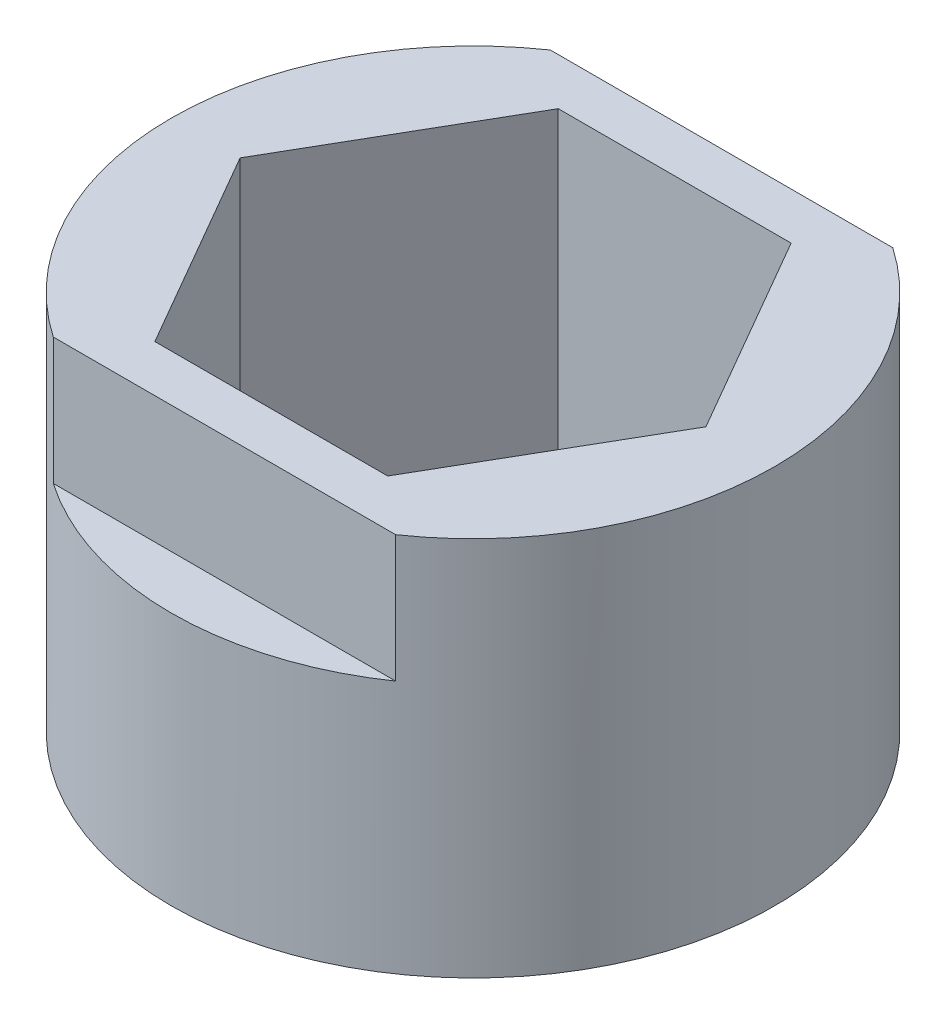
from build123d import *

# Parameters (mm, degrees)
SKETCH1_R               = 7.5565
BOSS_EXTRUDE1_DEPTH     = 8.89
SKETCH2_R               = 7.5565
SKETCH2_R_2             = 3.3
BOSS_EXTRUDE2_DEPTH     = 0.635
SKETCH3_W               = 1.979009817
SKETCH3_H               = 3.81
SKETCH3_W_2             = 2.256055482
CUT_EXTRUDE1_DEPTH      = 8.5565
CUT_EXTRUDE1_DEPTH_BACK = 8.5565


with BuildPart() as part:
    # Sketch1 → Boss-Extrude1 (new body)
    with BuildSketch(Plane(origin=(0, 0, 0), x_dir=(1, 0, 0), z_dir=(0, 1, 0))):
        Circle(SKETCH1_R)
        Polygon((-2.915618859, 5.05), (-5.831237719, 0), (-2.915618859, -5.05), (2.915618859, -5.05), (5.831237719, 0), (2.915618859, 5.05), align=None, mode=Mode.SUBTRACT)
    extrude(amount=BOSS_EXTRUDE1_DEPTH)

    # Sketch2 → Boss-Extrude2 (add)
    with BuildSketch(Plane.XZ):
        Circle(SKETCH2_R)
        Circle(SKETCH2_R_2, mode=Mode.SUBTRACT)
    extrude(amount=BOSS_EXTRUDE2_DEPTH)

    # Sketch3 → Cut-Extrude1 (cut, two sides)
    with BuildSketch(Plane(origin=(0, 0, 0), x_dir=(0, 0, -1), z_dir=(1, 0, 0))) as cut_extrude1_sk:
        with Locations((-7.212504909, 7.62)):
            Rectangle(SKETCH3_W, SKETCH3_H)
        with Locations((7.351027741, 7.62)):
            Rectangle(SKETCH3_W_2, SKETCH3_H)
    extrude(amount=CUT_EXTRUDE1_DEPTH, mode=Mode.SUBTRACT)
    extrude(cut_extrude1_sk.sketch, amount=-CUT_EXTRUDE1_DEPTH_BACK, mode=Mode.SUBTRACT)


solid = part.part
